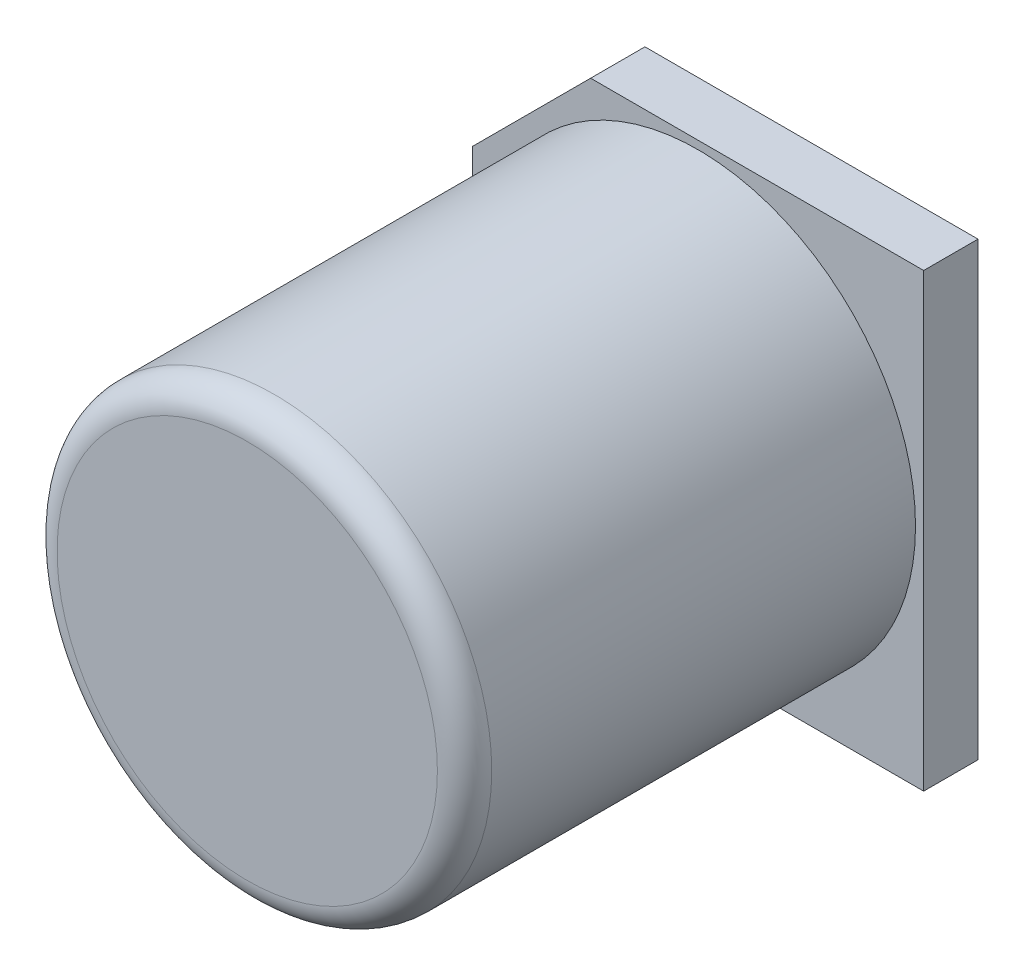
from build123d import *

# Parameters (mm, degrees)
BOSS_EXTRUDE1_DEPTH = 1
SKETCH3_R           = 4
BOSS_EXTRUDE2_DEPTH = 8.3
FILLET2_R           = 0.5


with BuildPart() as part:
    # Sketch2 → Boss-Extrude1 (new body)
    with BuildSketch(Plane.XY):
        Polygon((-1.98, 4.15), (-4.15, 1.98), (-4.15, -1.98), (-1.98, -4.15), (4.15, -4.15), (4.15, 4.15), align=None)
    extrude(amount=BOSS_EXTRUDE1_DEPTH)

    # Sketch3 → Boss-Extrude2 (add)
    with BuildSketch(Plane.XY.offset(1)):
        Circle(SKETCH3_R)
    extrude(amount=BOSS_EXTRUDE2_DEPTH)

    # Fillet2
    fillet2_edges = [part.edges().sort_by_distance(p)[0] for p in [
        (-4, 0, 9.3),
    ]]
    fillet(fillet2_edges, radius=FILLET2_R)


solid = part.part
